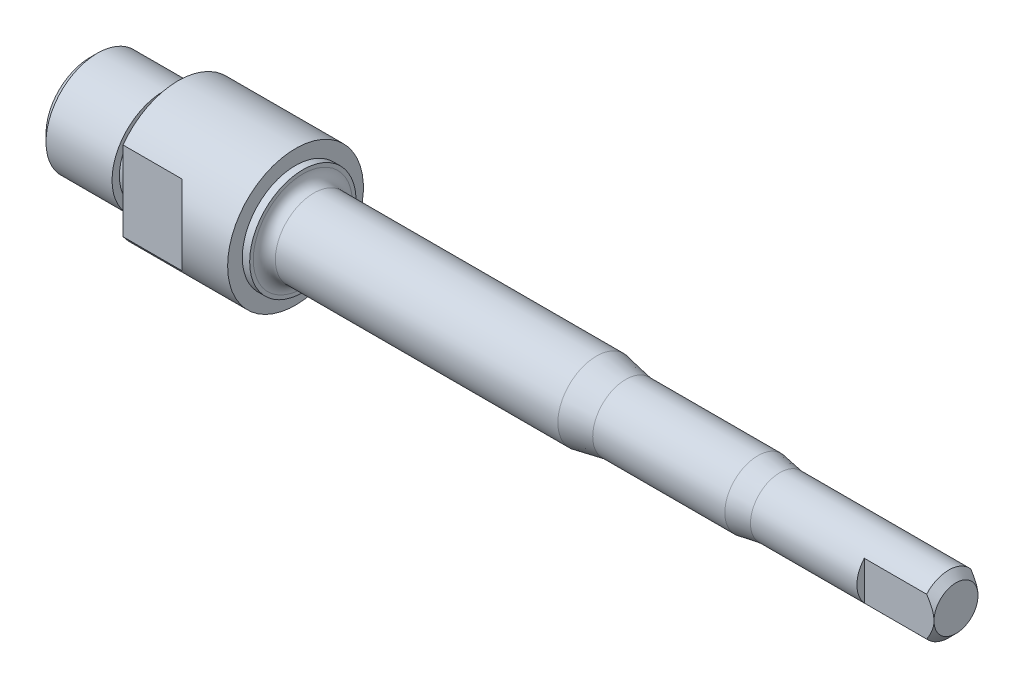
from build123d import *

# Parameters (mm, degrees)
CHANFREIN1_SIZE              = 1
ESQUISSE2_W                  = 9.5
ESQUISSE2_H                  = 1
ENL_V_MAT_EXTRU_1_DEPTH      = 10.25
ENL_V_MAT_EXTRU_1_DEPTH_BACK = 10.25
ENL_V_MAT_EXTRU_3_DEPTH      = 10.25
ENL_V_MAT_EXTRU_3_DEPTH_BACK = 10.25


with BuildPart() as part:
    # Esquisse1 → Révolution1 (revolve)
    with BuildSketch(Plane.XY, mode=Mode.PRIVATE) as r_volution1_sk:
        with BuildLine():
            Line((-30.5, 0), (-30.5, 7))
            Line((-30.5, 7), (-20.5, 7))
            Line((-20.5, 7), (-20.5, 6))
            Line((-20.5, 6), (-18.5, 6))
            Line((-18.5, 6), (-18.5, 9.25))
            Line((-18.5, 9.25), (-2.5, 9.25))
            Line((-2.5, 9.25), (-2.5, 7.25))
            Line((-2.5, 7.25), (-1.5, 7.25))
            Line((-1.5, 7.25), (-1.5, 6.75))
            ThreePointArc((-1.5, 6.75), (-1.060660172, 5.689339828), (0, 5.25))
            Line((0, 5.25), (38.5, 5.25))
            Line((38.5, 5.25), (42.5, 4.5))
            Line((42.5, 4.5), (60.5, 4.5))
            Line((60.5, 4.5), (63.5, 4))
            Line((63.5, 4), (87.5, 4))
            Line((87.5, 4), (87.5, 0))
            Line((87.5, 0), (-30.5, 0))
        make_face()
    revolve(r_volution1_sk.sketch.rotate(Axis((-56.136256415, 0, 0), (1, 0, 0)), 90), axis=Axis((-56.136256415, 0, 0), (1, 0, 0)))  # turned: the seam where the file's is

    # Chanfrein1
    chanfrein1_edges = [part.edges().sort_by_distance(p)[0] for p in [
        (87.5, 0, -4),
        (-30.5, 0, -7),
    ]]
    chamfer(chanfrein1_edges, length=CHANFREIN1_SIZE)

    # Esquisse2 → Enlèv. mat.-Extru.1 (cut, two sides)
    with BuildSketch(Plane(origin=(0, 0, 0), x_dir=(1, 0, 0), z_dir=(0, 1, 0))) as enl_v_mat_extru_1_sk:
        with Locations((82.75, 3.5)):
            Rectangle(ESQUISSE2_W, ESQUISSE2_H)
        with Locations((82.75, -3.5)):
            Rectangle(ESQUISSE2_W, ESQUISSE2_H)
    extrude(amount=ENL_V_MAT_EXTRU_1_DEPTH, mode=Mode.SUBTRACT)
    extrude(enl_v_mat_extru_1_sk.sketch, amount=-ENL_V_MAT_EXTRU_1_DEPTH_BACK, mode=Mode.SUBTRACT)

    # Esquisse4 → Enlèv. mat.-Extru.3 (cut, two sides)
    with BuildSketch(Plane(origin=(0, 0, 0), x_dir=(1, 0, 0), z_dir=(0, 1, 0))) as enl_v_mat_extru_3_sk:
        Polygon((-10.5, 7.5), (-8.75, 9.25), (-18.5, 9.25), (-18.5, 7.5), align=None)
        Polygon((-18.5, -7.5), (-10.5, -7.5), (-8.75, -9.25), (-18.5, -9.25), align=None)
    extrude(amount=ENL_V_MAT_EXTRU_3_DEPTH, mode=Mode.SUBTRACT)
    extrude(enl_v_mat_extru_3_sk.sketch, amount=-ENL_V_MAT_EXTRU_3_DEPTH_BACK, mode=Mode.SUBTRACT)


solid = part.part
